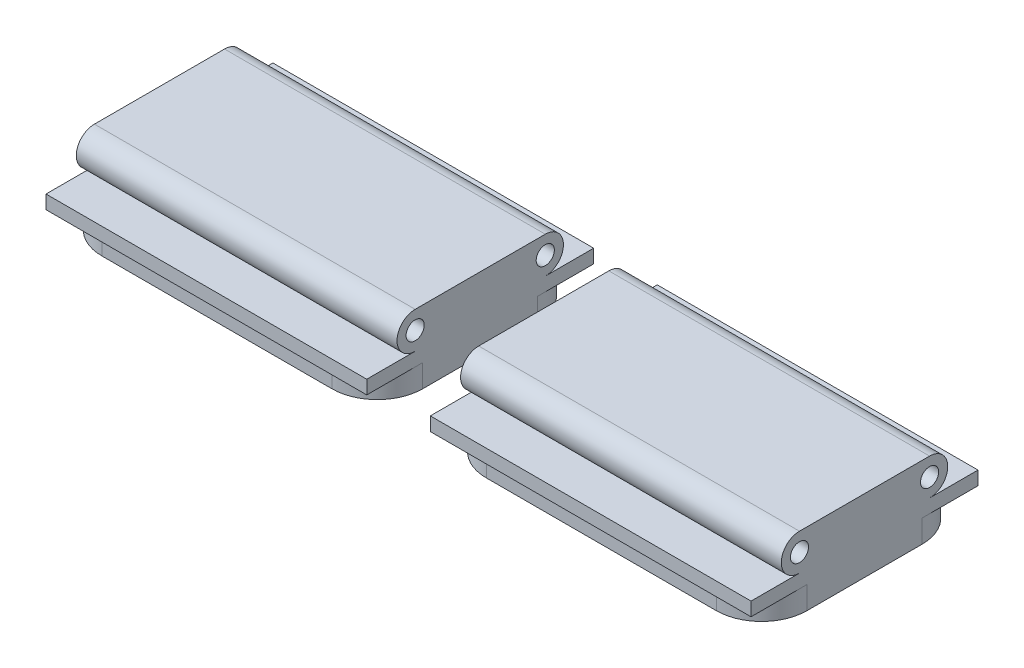
from build123d import *

# Parameters (mm, degrees)
IZIM1_R                     = 6
Y_KSEKLIK_EKSTR_ZYON1_DEPTH = 106
RADYUS1_R                   = 30


with BuildPart() as part:
    # Çizim1 → Yükseklik-Ekstrüzyon1 (new body, symmetric)
    with BuildSketch(Plane(origin=(0, 0, 0), x_dir=(0, 0, -1), z_dir=(1, 0, 0))):
        with BuildLine():
            Line((-43, -12), (43, -12))
            ThreePointArc((43, -12), (55, 0), (43, 12))
            Line((43, 12), (-43, 12))
            ThreePointArc((-43, 12), (-55, 0), (-43, -12))
        make_face()
        with Locations((43, 0)):
            Circle(IZIM1_R, mode=Mode.SUBTRACT)
        with Locations((-43, 0)):
            Circle(IZIM1_R, mode=Mode.SUBTRACT)
        Polygon((-75, -21), (-68, -21), (-68, -36), (68, -36), (68, -21), (75, -21), (75, -12), (43, -12), (-43, -12), (-75, -12), align=None)
    extrude(amount=Y_KSEKLIK_EKSTR_ZYON1_DEPTH, both=True)

    # Radyus1
    radyus1_edges = [part.edges().sort_by_distance(p)[0] for p in [
        (-106, -28.5, -68),
        (-106, -28.5, 68),
        (106, -28.5, 68),
        (106, -28.5, -68),
    ]]
    fillet(radyus1_edges, radius=RADYUS1_R)


with BuildPart() as body_2:
    # Aynalama16: mirrored copy
    add(part.part.mirror(Plane.ZY.offset(127)))


solid = Compound([part.part, body_2.part])
